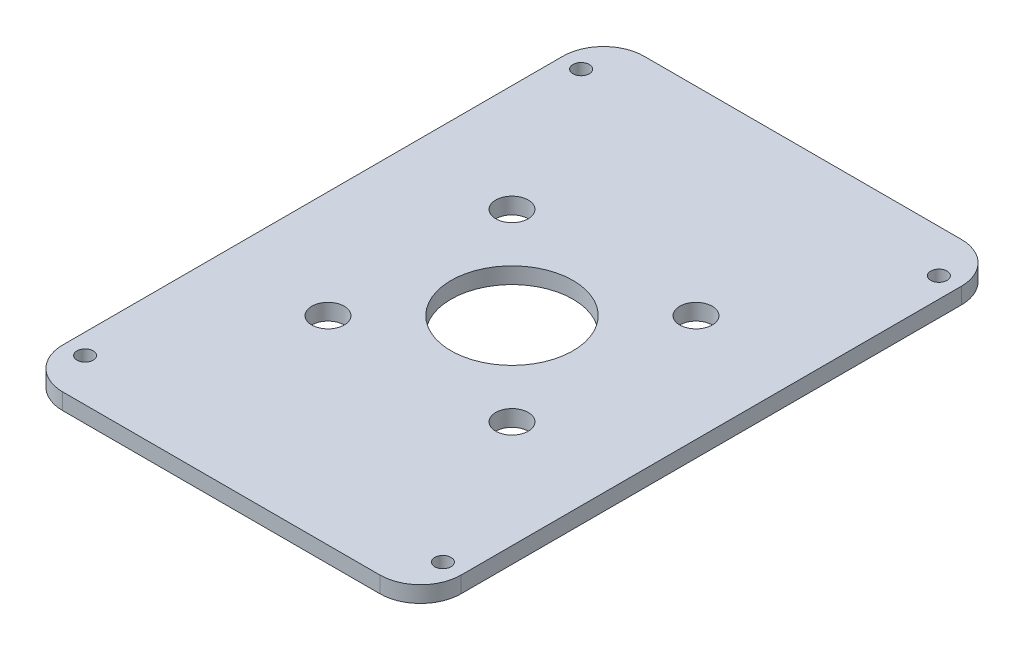
from build123d import *

# Parameters (mm, degrees)
SKETCH2_W           = 49
SKETCH2_H           = 71.5
BOSS_EXTRUDE1_DEPTH = 2
SKETCH2_6_R         = 1
SKETCH2_6_R_2       = 7.5
SKETCH2_6_R_3       = 2
CUT_EXTRUDE2_DEPTH  = 10
FILLET1_R           = 5


with BuildPart() as part:
    # Sketch2 → Boss-Extrude1 (new body)
    with BuildSketch(Plane(origin=(0, 0, 0), x_dir=(1, 0, 0), z_dir=(0, 1, 0))):
        Rectangle(SKETCH2_W, SKETCH2_H)
    extrude(amount=BOSS_EXTRUDE1_DEPTH)

    # Sketch2_6 → Cut-Extrude2 (cut)
    with BuildSketch(Plane(origin=(0, 0, 0), x_dir=(1, 0, 0), z_dir=(0, 1, 0))):
        with Locations((-22, 30.5)):
            Circle(SKETCH2_6_R)
        with Locations((22, 30.5)):
            Circle(SKETCH2_6_R)
        with Locations((-22, -30.5)):
            Circle(SKETCH2_6_R)
        with Locations((22, -30.5)):
            Circle(SKETCH2_6_R)
        Circle(SKETCH2_6_R_2)
        with Locations((11.313708499, 11.313708499)):
            Circle(SKETCH2_6_R_3)
        with Locations((11.313708499, -11.313708499)):
            Circle(SKETCH2_6_R_3)
        with Locations((-11.313708499, -11.313708499)):
            Circle(SKETCH2_6_R_3)
        with Locations((-11.313708499, 11.313708499)):
            Circle(SKETCH2_6_R_3)
    extrude(amount=CUT_EXTRUDE2_DEPTH, mode=Mode.SUBTRACT)

    # Fillet1
    fillet1_edges = [part.edges().sort_by_distance(p)[0] for p in [
        (24.5, 1, -35.75),
        (-24.5, 1, -35.75),
        (-24.5, 1, 35.75),
        (24.5, 1, 35.75),
    ]]
    fillet(fillet1_edges, radius=FILLET1_R)


solid = part.part
